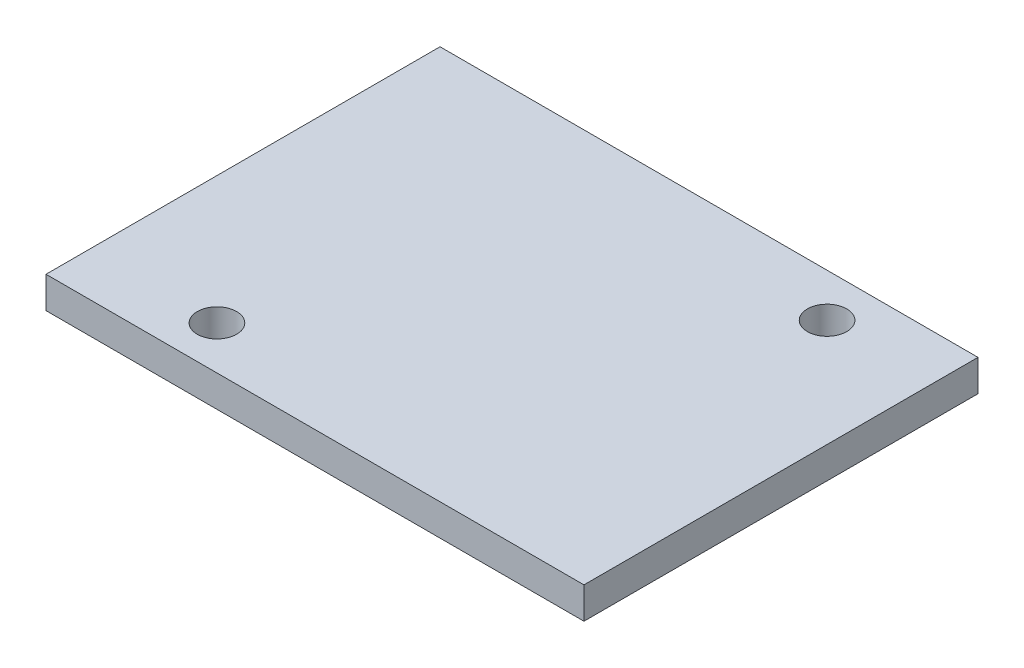
from build123d import *

# Parameters (mm, degrees)
SKETCH1_W           = 27.305
SKETCH1_H           = 20
BOSS_EXTRUDE1_DEPTH = 1.6002
SKETCH2_R           = 1
CUT_EXTRUDE1_DEPTH  = 1.6002


with BuildPart() as part:
    # Sketch1 → Boss-Extrude1 (new body)
    with BuildSketch(Plane(origin=(0, 0, 0), x_dir=(1, 0, 0), z_dir=(0, 1, 0))):
        Rectangle(SKETCH1_W, SKETCH1_H)
    extrude(amount=BOSS_EXTRUDE1_DEPTH)

    # Sketch2 → Cut-Extrude1 (cut)
    with BuildSketch(Plane(origin=(0, 1.6002, 0), x_dir=(1, 0, 0), z_dir=(0, 1, 0))):
        with Locations((-7.1755, -7.8)):
            Circle(SKETCH2_R)
        with Locations((8.1915, 7.8)):
            Circle(SKETCH2_R)
    extrude(amount=-CUT_EXTRUDE1_DEPTH, mode=Mode.SUBTRACT)


solid = part.part
